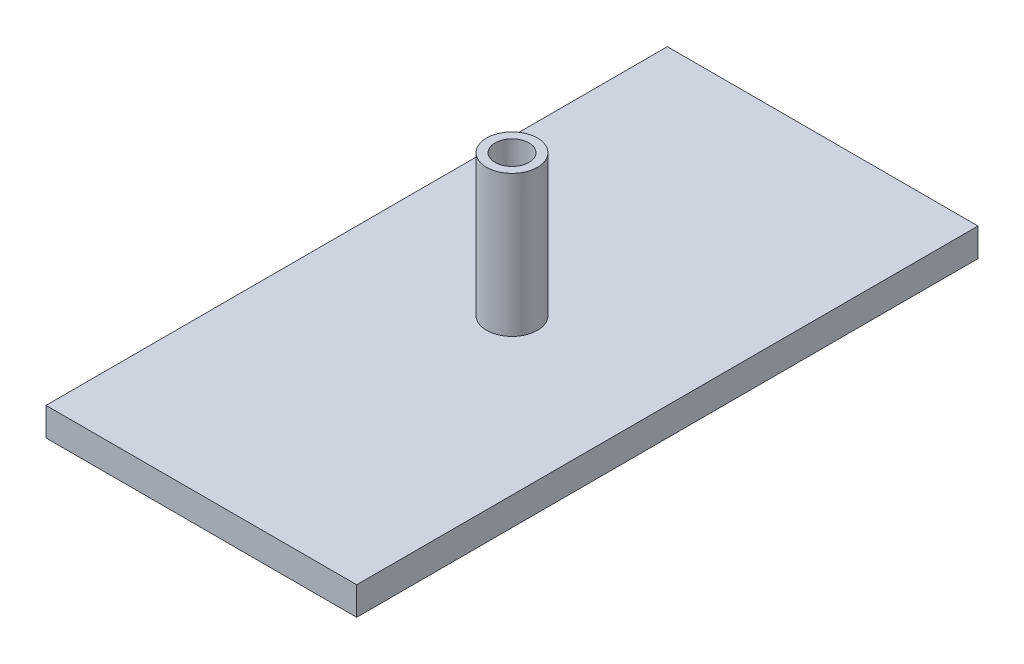
from build123d import *

# Parameters (mm, degrees)
SKETCH1_W           = 55
SKETCH1_H           = 110
BOSS_EXTRUDE3_DEPTH = 5
SKETCH3_R           = 4.5
BOSS_EXTRUDE4_DEPTH = 25
SKETCH4_R           = 3
CUT_EXTRUDE1_DEPTH  = 20


with BuildPart() as part:
    # Sketch1 → Boss-Extrude3 (new body)
    with BuildSketch(Plane(origin=(0, 0, 0), x_dir=(1, 0, 0), z_dir=(0, 1, 0))):
        with Locations((27.5, 55)):
            Rectangle(SKETCH1_W, SKETCH1_H)
    extrude(amount=BOSS_EXTRUDE3_DEPTH)

    # Sketch3 → Boss-Extrude4 (add)
    with BuildSketch(Plane(origin=(0, 5, 0), x_dir=(1, 0, 0), z_dir=(0, 1, 0))):
        with Locations((27.5, 55)):
            Circle(SKETCH3_R)
    extrude(amount=BOSS_EXTRUDE4_DEPTH)

    # Sketch4 → Cut-Extrude1 (cut)
    with BuildSketch(Plane(origin=(0, 30, 0), x_dir=(1, 0, 0), z_dir=(0, 1, 0))):
        with Locations((27.5, 55)):
            Circle(SKETCH4_R)
    extrude(amount=-CUT_EXTRUDE1_DEPTH, mode=Mode.SUBTRACT)


solid = part.part
